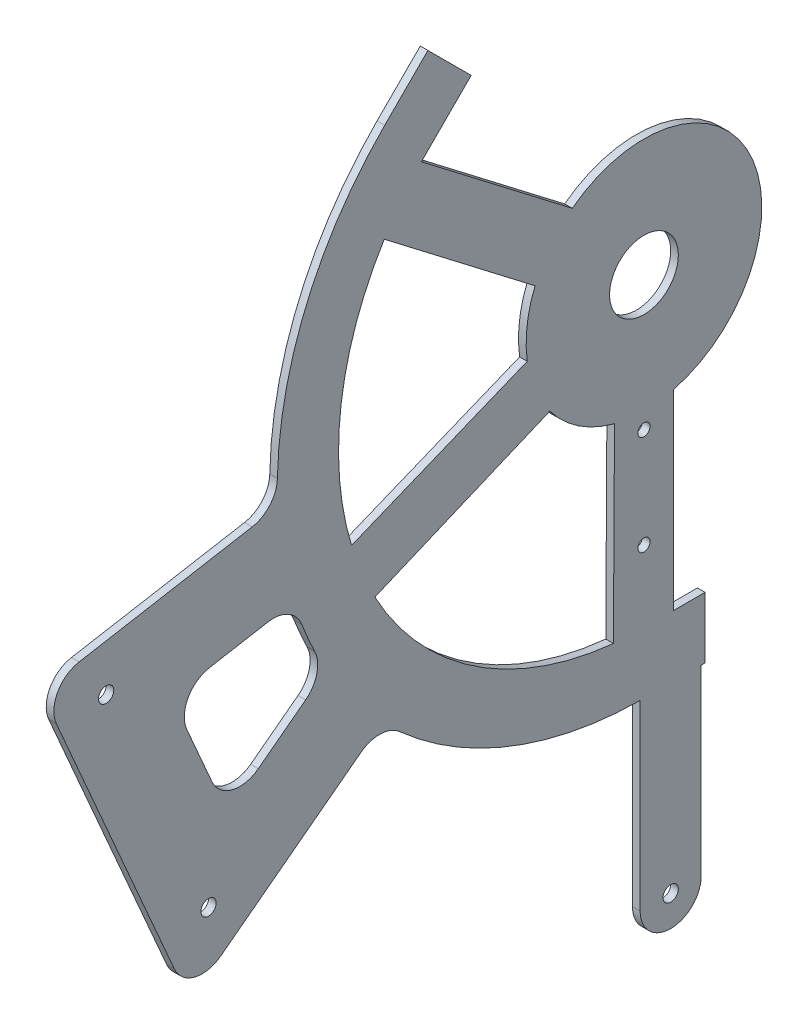
from build123d import *

# Parameters (mm, degrees)
BOSS_EXTRUDE2_DEPTH = 3.175
SKETCH11_W          = 25.4
SKETCH11_H          = 25.436159883
BOSS_EXTRUDE4_DEPTH = 3.175
SKETCH12_R          = 3.175
BOSS_EXTRUDE5_DEPTH = 3.175
SKETCH13_R          = 3.175
BOSS_EXTRUDE6_DEPTH = 3.175
SKETCH14_R          = 14.2875
BOSS_EXTRUDE7_DEPTH = 3.175
SKETCH15_R          = 3.175
SKETCH15_R_2        = 2.54
CUT_EXTRUDE1_DEPTH  = 4.175


with BuildPart() as part:
    # Sketch9 → Boss-Extrude2 (new body)
    with BuildSketch(Plane(origin=(0, 0, 0), x_dir=(0, 0, -1), z_dir=(1, 0, 0))):
        with BuildLine():
            Line((0, -126.954378983), (0, -152.390538866))
            ThreePointArc((0, -152.390538866), (-140.790499807, -58.317334473), (-107.756383421, 107.756383421))
            Line((-107.756383421, 107.756383421), (-89.795871179, 125.716895663))
            Line((-89.795871179, 125.716895663), (-71.809790038, 107.730814523))
            Line((-71.809790038, 107.730814523), (-89.770302281, 89.770302281))
            ThreePointArc((-89.770302281, 89.770302281), (-117.290552306, -48.583337503), (0, -126.954378983))
        make_face()
    extrude(amount=BOSS_EXTRUDE2_DEPTH)

    # Sketch11 → Boss-Extrude4 (add)
    with BuildSketch(Plane(origin=(0, 0, 0), x_dir=(0, 0, -1), z_dir=(1, 0, 0))):
        with Locations((12.7, -139.672458925)):
            Rectangle(SKETCH11_W, SKETCH11_H)
    extrude(amount=BOSS_EXTRUDE4_DEPTH)

    # Sketch12 → Boss-Extrude5 (add)
    with BuildSketch(Plane(origin=(0, 0, 0), x_dir=(0, 0, -1), z_dir=(1, 0, 0))):
        with BuildLine():
            ThreePointArc((-1.596710848, -228.181271676), (11.103289152, -240.881271676), (23.803289152, -228.181271676))
            Line((23.803289152, -228.181271676), (23.803289152, -152.390538866))
            Line((23.803289152, -152.390538866), (0, -152.390538866))
            ThreePointArc((0, -152.390538866), (-0.79836638, -152.388447551), (-1.596710848, -152.382173664))
            Line((-1.596710848, -152.382173664), (-1.596710848, -228.181271676))
        make_face()
        with Locations((11.103289152, -228.181271676)):
            Circle(SKETCH12_R, mode=Mode.SUBTRACT)
    extrude(amount=BOSS_EXTRUDE5_DEPTH)

    # Sketch13 → Boss-Extrude6 (add)
    with BuildSketch(Plane(origin=(0, 0, 0), x_dir=(0, 0, -1), z_dir=(1, 0, 0))):
        with BuildLine():
            Line((-175.921744047, -157.217647079), (-117.615441364, -113.032446562))
            ThreePointArc((-117.615441364, -113.032446562), (-109.43511183, -110.464604073), (-101.487144145, -113.680411283))
            ThreePointArc((-101.487144145, -113.680411283), (-121.45550521, -92.040407377), (-136.889329567, -66.964078331))
            ThreePointArc((-136.889329567, -66.964078331), (-135.942652679, -75.485545881), (-140.626971786, -82.666685125))
            Line((-140.626971786, -82.666685125), (-160.306949591, -97.58040329))
            ThreePointArc((-160.306949591, -97.58040329), (-171.19425961, -99.744336405), (-179.624122676, -92.522595986))
            Line((-179.624122676, -92.522595986), (-190.009209059, -68.638532465))
            ThreePointArc((-190.009209059, -68.638532465), (-189.548026602, -57.559851452), (-180.560256724, -51.066019389))
            Line((-180.560256724, -51.066019389), (-156.267984197, -46.797896728))
            ThreePointArc((-156.267984197, -46.797896728), (-147.818260582, -48.251780205), (-142.218034883, -54.744012368))
            ThreePointArc((-142.218034883, -54.744012368), (-150.091480412, -26.370890083), (-152.361266177, 2.986788389))
            ThreePointArc((-152.361266177, 2.986788389), (-155.413049284, -5.02559117), (-162.861116025, -9.272697026))
            Line((-162.861116025, -9.272697026), (-234.783717211, -21.90941035))
            ThreePointArc((-234.783717211, -21.90941035), (-243.771487088, -28.403242413), (-244.232669546, -39.481923426))
            Line((-244.232669546, -39.481923426), (-195.238917132, -152.159839775))
            ThreePointArc((-195.238917132, -152.159839775), (-186.809054067, -159.381580194), (-175.921744047, -157.217647079))
        make_face()
        with Locations((-180.989788445, -137.156185968)):
            Circle(SKETCH13_R, mode=Mode.SUBTRACT)
        with Locations((-223.548763187, -39.27724509)):
            Circle(SKETCH13_R, mode=Mode.SUBTRACT)
    extrude(amount=BOSS_EXTRUDE6_DEPTH)

    # Sketch14 → Boss-Extrude7 (add)
    with BuildSketch(Plane(origin=(0, 0, 0), x_dir=(0, 0, -1), z_dir=(1, 0, 0))):
        with BuildLine():
            Line((-29.799778624, 38.874174032), (-100.328890576, 92.993065071))
            Line((-100.328890576, 92.993065071), (-115.791430873, 72.841890227))
            Line((-115.791430873, 72.841890227), (-45.262318921, 18.722999189))
            ThreePointArc((-45.262318921, 18.722999189), (-48.592985775, 6.160352763), (-48.502549248, -6.836002425))
            Line((-48.502549248, -6.836002425), (-121.562281943, -36.60636491))
            ThreePointArc((-121.562281943, -36.60636491), (-117.290552306, -48.583337503), (-111.842122761, -60.072905036))
            Line((-111.842122761, -60.072905036), (-39.130265149, -29.462697807))
            ThreePointArc((-39.130265149, -29.462697807), (-27.212895153, -40.726975705), (-12.2454793, -47.426537396))
            Line((-12.2454793, -47.426537396), (-12.7, -126.317553583))
            ThreePointArc((-12.7, -126.317553583), (-6.357978189, -126.795072682), (0, -126.954378983))
            Line((0, -126.954378983), (12.2454793, -126.954378983))
            Line((12.2454793, -126.954378983), (12.2454793, -47.426537396))
            ThreePointArc((12.2454793, -47.426537396), (44.033981815, 21.453127004), (-29.799778624, 38.874174032))
        make_face()
        Circle(SKETCH14_R, mode=Mode.SUBTRACT)
    extrude(amount=BOSS_EXTRUDE7_DEPTH)

    # Sketch15 → Cut-Extrude1 (cut, through all)
    with BuildSketch(Plane(origin=(3.175, 0, 0), x_dir=(0, 0, -1), z_dir=(1, 0, 0))):
        with Locations((11.103289152, -228.181271676)):
            Circle(SKETCH15_R)
        with Locations((0, -55.741886393)):
            Circle(SKETCH15_R_2)
        with Locations((0, -97.196272786)):
            Circle(SKETCH15_R_2)
    extrude(amount=-CUT_EXTRUDE1_DEPTH, mode=Mode.SUBTRACT)


solid = part.part
